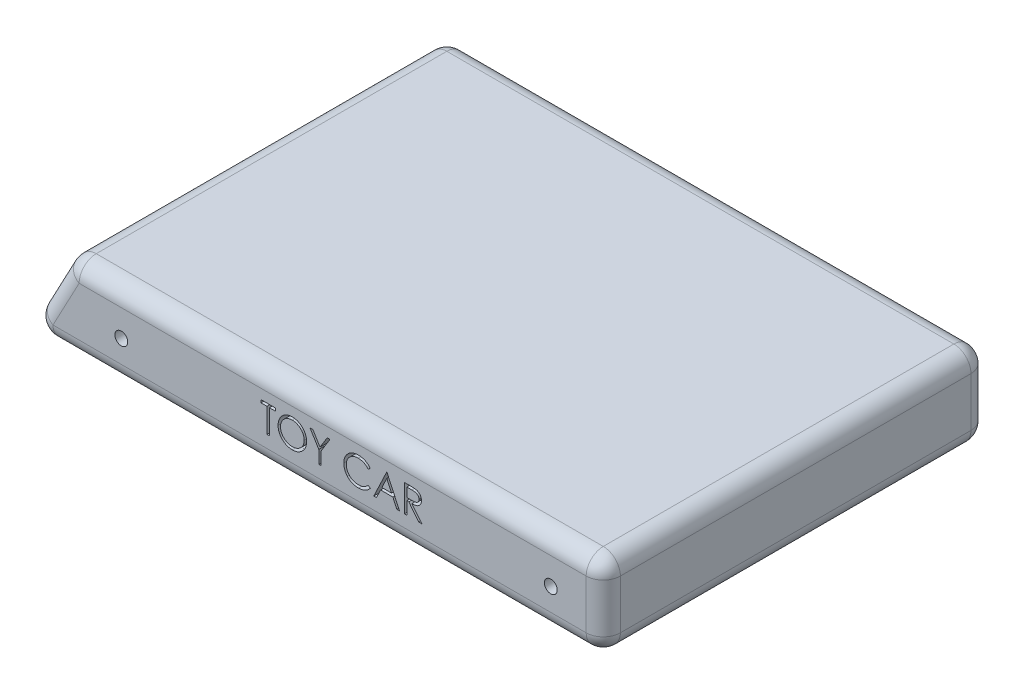
from build123d import *

# Parameters (mm, degrees)
SKETCH1_W               = 250
SKETCH1_H               = 180
BOSS_EXTRUDE1_DEPTH     = 39
SKETCH2_R               = 3
CUT_EXTRUDE2_DEPTH      = 91
CUT_EXTRUDE2_DEPTH_BACK = 91
DRAFT1_ANGLE            = 28
FILLET1_R               = 8
CUT_EXTRUDE3_DEPTH      = 8
CUT_EXTRUDE3_DEPTH_BACK = 8


with BuildPart() as part:
    # Sketch1 → Boss-Extrude1 (new body)
    with BuildSketch(Plane(origin=(0, 0, 0), x_dir=(1, 0, 0), z_dir=(0, 1, 0))):
        Rectangle(SKETCH1_W, SKETCH1_H)
    extrude(amount=BOSS_EXTRUDE1_DEPTH)

    # Sketch2 → Cut-Extrude2 (cut, two sides)
    with BuildSketch(Plane.XY) as cut_extrude2_sk:
        with Locations((100.46336903, 18.512298338)):
            Circle(SKETCH2_R)
        with Locations((-100.46336903, 18.512298338)):
            Circle(SKETCH2_R)
    extrude(amount=CUT_EXTRUDE2_DEPTH, mode=Mode.SUBTRACT)
    extrude(cut_extrude2_sk.sketch, amount=-CUT_EXTRUDE2_DEPTH_BACK, mode=Mode.SUBTRACT)

    # Draft1
    draft1_faces = [part.faces().sort_by_distance(p)[0] for p in [
        (-125, 19.5, 0),
    ]]
    draft(draft1_faces, Plane.ZX.offset(39), DRAFT1_ANGLE)

    # Fillet1
    fillet1_edges = [part.edges().sort_by_distance(p)[0] for p in [
        (-125, 39, 0),
        (0, 39, 90),
        (125, 39, 0),
        (-10.368333917, 0, 90),
        (-145.736667835, 0, 0),
        (-10.368333917, 0, -90),
        (125, 0, 0),
        (0, 39, -90),
        (125, 19.5, 90),
        (-135.368333917, 19.5, 90),
        (-135.368333917, 19.5, -90),
        (125, 19.5, -90),
    ]]
    fillet(fillet1_edges, radius=FILLET1_R)

    # Sketch3 → Cut-Extrude3 (cut, two sides)
    with BuildSketch(Plane.XY.offset(83)) as cut_extrude3_sk:
        Polygon((-35.112238837, 25.112326164), (-35.112238837, 26.414890267), (-28.436597812, 26.414890267), (-28.436597812, 25.112326164), (-31.20454653, 25.112326164), (-31.20454653, 13.714890267), (-32.34429012, 13.714890267), (-32.34429012, 25.112326164), align=None)
        with BuildLine():
            add(Edge.make_bspline(
                [(-20.53980294, 26.740531292), (-20.304642099, 26.734575067), (-19.842766804, 26.722876549), (-19.163952175, 26.633326659), (-18.515907115, 26.478403387), (-17.893352612, 26.272071994), (-17.30373524, 25.996828938), (-16.742616972, 25.664142828), (-16.211332887, 25.27052825), (-15.717043874, 24.819027912), (-15.264717226, 24.327779379), (-14.866206153, 23.803530963), (-14.532224116, 23.249452452), (-14.257955688, 22.667208866), (-14.042786447, 22.058116982), (-13.894308775, 21.418929601), (-13.79946463, 20.753788183), (-13.788376523, 20.300119274), (-13.782751658, 20.069978408)],
                knots=[0, 0, 0, 0, 0.000705368, 0.001385402, 0.00204938, 0.002701839, 0.003349503, 0.003997423, 0.004655841, 0.005329419, 0.006002834, 0.006656665, 0.007301525, 0.007939971, 0.008584465, 0.009235478, 0.009905767, 0.010595886, 0.010595886, 0.010595886, 0.010595886], degree=3))
            add(Edge.make_bspline(
                [(-13.782751658, 20.069978408), (-13.788375699, 19.841532817), (-13.799461335, 19.391240091), (-13.894416613, 18.730319594), (-14.043336813, 18.094990495), (-14.255957551, 17.486313412), (-14.528918572, 16.903646252), (-14.865124479, 16.348522162), (-15.261151158, 15.820759154), (-15.711844589, 15.326138911), (-16.203156941, 14.872576661), (-16.730135338, 14.47735674), (-17.280928242, 14.13727206), (-17.862623469, 13.865914157), (-18.467506459, 13.649027474), (-19.100990889, 13.501153645), (-19.760108385, 13.405769231), (-20.20958317, 13.39481633), (-20.43804012, 13.389249241)],
                knots=[0, 0, 0, 0, 0.000685036, 0.001350284, 0.001998823, 0.002640075, 0.003280822, 0.003925683, 0.00458358, 0.005257158, 0.005930573, 0.006586435, 0.007230442, 0.007868887, 0.008508583, 0.009154647, 0.009817376, 0.010502411, 0.010502411, 0.010502411, 0.010502411], degree=3))
            add(Edge.make_bspline(
                [(-20.43804012, 13.389249241), (-20.668179791, 13.394871302), (-21.121846346, 13.40595388), (-21.787823589, 13.500954978), (-22.427459974, 13.649513423), (-23.038926334, 13.861819092), (-23.62256365, 14.136201614), (-24.179513378, 14.47077179), (-24.707539998, 14.867763416), (-25.202265764, 15.318310701), (-25.65492714, 15.808790333), (-26.049568304, 16.334331773), (-26.384213715, 16.88462443), (-26.65767495, 17.461195446), (-26.874171702, 18.061257538), (-27.021872043, 18.688813442), (-27.117433926, 19.340285363), (-27.128446083, 19.783852451), (-27.134033709, 20.008920715)],
                knots=[0, 0, 0, 0, 0.000690119, 0.001360408, 0.002013897, 0.002657552, 0.003298299, 0.003945339, 0.004603236, 0.005276814, 0.005950229, 0.006602529, 0.007245213, 0.007879059, 0.008513962, 0.009155077, 0.009810248, 0.010485118, 0.010485118, 0.010485118, 0.010485118], degree=3))
            add(Edge.make_bspline(
                [(-27.134033709, 20.008920715), (-27.132093746, 20.159987829), (-27.128238293, 20.460216277), (-27.081822724, 20.906046512), (-27.014470265, 21.344706899), (-26.917943325, 21.774950053), (-26.791699276, 22.195722769), (-26.642739063, 22.609926965), (-26.460803052, 23.013365049), (-26.255133272, 23.407948213), (-26.025583283, 23.787525471), (-25.772034135, 24.146317101), (-25.503391512, 24.487333861), (-25.208884341, 24.801738704), (-24.898218954, 25.098677971), (-24.566355697, 25.373588401), (-24.215319553, 25.628948938), (-23.843600061, 25.859074175), (-23.460356606, 26.067205892), (-23.065289441, 26.245810895), (-22.663764167, 26.399103746), (-22.253900159, 26.523349026), (-21.836785815, 26.6214367), (-21.411510768, 26.688229098), (-20.978413821, 26.734763051), (-20.686635606, 26.738600273), (-20.53980294, 26.740531292)],
                knots=[0, 0, 0, 0, 0.000453023, 0.000900331, 0.00134327, 0.001783953, 0.002221843, 0.002660465, 0.003103469, 0.003548398, 0.003994743, 0.004433047, 0.004865726, 0.005295975, 0.005724256, 0.006154227, 0.006587795, 0.007025471, 0.007464852, 0.007895214, 0.008325184, 0.00875333, 0.009179133, 0.00960951, 0.010044159, 0.010484467, 0.010484467, 0.010484467, 0.010484467], degree=3))
        make_face()
        with BuildLine():
            add(Edge.make_bspline(
                [(-20.483833389, 25.43796719), (-20.604355059, 25.436498016), (-20.844246204, 25.433573715), (-21.200878664, 25.395053833), (-21.552820824, 25.34015395), (-21.900145367, 25.261843861), (-22.241399046, 25.155149155), (-22.579762755, 25.032355002), (-22.912150979, 24.882781331), (-23.237466406, 24.713788946), (-23.552843964, 24.526740005), (-23.85043291, 24.320013879), (-24.131003646, 24.098458554), (-24.393869214, 23.861556972), (-24.638257753, 23.608102703), (-24.868979384, 23.341938149), (-25.076786152, 23.055455573), (-25.267233816, 22.756423525), (-25.437659979, 22.445231502), (-25.589208552, 22.125155716), (-25.713175099, 21.793585253), (-25.814275721, 21.454117309), (-25.898095035, 21.107289527), (-25.951195274, 20.750470876), (-25.990138406, 20.385454326), (-25.99289556, 20.138777313), (-25.99429012, 20.014008856)],
                knots=[0, 0, 0, 0, 0.000361401, 0.000719348, 0.001074863, 0.001429731, 0.001786237, 0.002146831, 0.002508984, 0.002878794, 0.003246164, 0.003608191, 0.003964987, 0.004318036, 0.004668869, 0.005020697, 0.005373837, 0.005729543, 0.006083645, 0.0064376, 0.006791042, 0.007144375, 0.007499817, 0.007860358, 0.0082259, 0.008600016, 0.008600016, 0.008600016, 0.008600016], degree=3))
            add(Edge.make_bspline(
                [(-25.99429012, 20.014008856), (-25.989664192, 19.830540227), (-25.980563561, 19.469600674), (-25.900888949, 18.940670552), (-25.778163499, 18.432350198), (-25.597252484, 17.947420985), (-25.371008825, 17.481714587), (-25.091511252, 17.039362321), (-24.760371141, 16.620244634), (-24.38422063, 16.227287516), (-23.973021095, 15.868618455), (-23.536385189, 15.553791229), (-23.078990671, 15.287416894), (-22.599644764, 15.070409917), (-22.100906551, 14.898452868), (-21.579562294, 14.780601835), (-21.039084912, 14.703039469), (-20.670673678, 14.695590897), (-20.483833389, 14.691813343)],
                knots=[0, 0, 0, 0, 0.000550108, 0.001082232, 0.001601154, 0.002116289, 0.002631707, 0.003151905, 0.003682739, 0.004231557, 0.004781529, 0.005317417, 0.005844089, 0.006366671, 0.006893638, 0.007423745, 0.007968111, 0.008528275, 0.008528275, 0.008528275, 0.008528275], degree=3))
            add(Edge.make_bspline(
                [(-20.483833389, 14.691813343), (-20.35825034, 14.693538745), (-20.109181437, 14.696960735), (-19.738720541, 14.731427362), (-19.374933716, 14.786697288), (-19.018331215, 14.866274238), (-18.669317756, 14.965868387), (-18.326436613, 15.084187857), (-17.99333996, 15.231802511), (-17.665825691, 15.394899364), (-17.352330757, 15.580827935), (-17.053062397, 15.780537793), (-16.775563842, 16.001766788), (-16.512894925, 16.235148565), (-16.267503025, 16.485388813), (-16.041047568, 16.752162189), (-15.834291089, 17.037152574), (-15.643915742, 17.335731046), (-15.47408676, 17.647774592), (-15.326116887, 17.969010852), (-15.200582409, 18.29864882), (-15.099241835, 18.637163951), (-15.019828874, 18.983913316), (-14.965110307, 19.3393612), (-14.926834544, 19.702796528), (-14.92394955, 19.948609949), (-14.922495248, 20.072522478)],
                knots=[0, 0, 0, 0, 0.00037666, 0.00074703, 0.001115112, 0.001479909, 0.001842294, 0.002203561, 0.002567016, 0.002934509, 0.003300581, 0.003659737, 0.00401296, 0.004364308, 0.004713319, 0.005063497, 0.005413082, 0.005768788, 0.006125121, 0.006478005, 0.006829068, 0.007182401, 0.00753727, 0.007895297, 0.008260839, 0.008632412, 0.008632412, 0.008632412, 0.008632412], degree=3))
            add(Edge.make_bspline(
                [(-14.922495248, 20.072522478), (-14.923950715, 20.195587308), (-14.926837902, 20.439709067), (-14.965092024, 20.800609751), (-15.019886683, 21.153499975), (-15.098854224, 21.496994346), (-15.20063621, 21.831180423), (-15.326138809, 22.155744336), (-15.474131182, 22.471895215), (-15.643978167, 22.778851664), (-15.834898441, 23.073399999), (-16.04352041, 23.354985896), (-16.273446101, 23.618321272), (-16.518106249, 23.869907162), (-16.783612033, 24.10437779), (-17.068760757, 24.321810936), (-17.370090673, 24.52745396), (-17.689140928, 24.712966713), (-18.018411846, 24.884286929), (-18.356282493, 25.031066283), (-18.698925226, 25.155787973), (-19.045468719, 25.262166675), (-19.398829812, 25.339847242), (-19.756620848, 25.395103308), (-20.118346815, 25.433560308), (-20.361617927, 25.436493568), (-20.483833389, 25.43796719)],
                knots=[0, 0, 0, 0, 0.000369031, 0.00073204, 0.001087555, 0.001439943, 0.001788407, 0.002134718, 0.002482986, 0.00283486, 0.003186283, 0.003535331, 0.003885231, 0.004234241, 0.004587492, 0.004946738, 0.005309426, 0.005681174, 0.006053244, 0.006422379, 0.006785362, 0.007146737, 0.00750905, 0.007869591, 0.0082326, 0.008599088, 0.008599088, 0.008599088, 0.008599088], degree=3))
        make_face(mode=Mode.SUBTRACT)
        Polygon((-12.15454653, 26.414890267), (-10.849438357, 26.414890267), (-7.511617844, 20.957859017), (-4.178885472, 26.414890267), (-2.873777299, 26.414890267), (-6.94429012, 19.751969593), (-6.94429012, 13.714890267), (-8.084033709, 13.714890267), (-8.084033709, 19.751969593), align=None)
        with BuildLine():
            Line((16.013402188, 24.084521677), (15.016126547, 23.321300523))
            add(Edge.make_bspline(
                [(15.016126547, 23.321300523), (14.944985181, 23.406085613), (14.803661588, 23.574512708), (14.576298196, 23.81102134), (14.33934652, 24.032601003), (14.092897138, 24.240307252), (13.832514047, 24.426876659), (13.564504863, 24.602031804), (13.284386242, 24.759031882), (12.897029948, 24.949397575), (12.390307755, 25.148047908), (11.752423625, 25.314611062), (11.086540496, 25.420642185), (10.632252063, 25.432126038), (10.401182637, 25.43796719)],
                knots=[0, 0, 0, 0, 0.00033196, 0.000659444, 0.000983431, 0.001304932, 0.001625525, 0.001943778, 0.002265016, 0.002588143, 0.003238217, 0.003893566, 0.004562806, 0.005255583, 0.005255583, 0.005255583, 0.005255583], degree=3))
            add(Edge.make_bspline(
                [(10.401182637, 25.43796719), (10.273880379, 25.436501383), (10.020457349, 25.433583373), (9.64436146, 25.395087405), (9.275288388, 25.340981014), (8.913478211, 25.260697698), (8.559391476, 25.159197052), (8.210713331, 25.03791055), (7.872492012, 24.88785156), (7.54004869, 24.721995873), (7.221535553, 24.534662002), (6.92016438, 24.330324983), (6.637034325, 24.111271404), (6.371921418, 23.876680247), (6.124554634, 23.62760799), (5.896726392, 23.361400237), (5.689225046, 23.078908064), (5.497937555, 22.783856557), (5.32662278, 22.477105141), (5.183185789, 22.157518457), (5.056167203, 21.830569283), (4.955658522, 21.492563643), (4.876103847, 21.145879892), (4.82121204, 20.789587604), (4.783153873, 20.42443111), (4.780250374, 20.176928747), (4.778786804, 20.052169914)],
                knots=[0, 0, 0, 0, 0.000381746, 0.00075995, 0.001133062, 0.001500343, 0.001870765, 0.002237676, 0.002606812, 0.002979993, 0.003351741, 0.00371443, 0.004071661, 0.004424911, 0.004775707, 0.005123948, 0.005475039, 0.005826461, 0.006178335, 0.006527846, 0.006876532, 0.007229865, 0.007584733, 0.007942761, 0.008310834, 0.008684951, 0.008684951, 0.008684951, 0.008684951], degree=3))
            add(Edge.make_bspline(
                [(4.778786804, 20.052169914), (4.783365404, 19.864459125), (4.792354879, 19.495913888), (4.872358834, 18.956089101), (4.993934451, 18.438942656), (5.176145258, 17.947707229), (5.400822956, 17.476325472), (5.684724604, 17.032773061), (6.013533182, 16.610347241), (6.391900361, 16.219031403), (6.807030036, 15.861567314), (7.252429601, 15.546786632), (7.726989731, 15.284386916), (8.225470647, 15.066034196), (8.75170826, 14.898188355), (9.304756257, 14.780027107), (9.883411783, 14.702948338), (10.278815034, 14.695568955), (10.480048823, 14.691813343)],
                knots=[0, 0, 0, 0, 0.000562815, 0.001105012, 0.001633818, 0.00215373, 0.002673724, 0.003197432, 0.003730267, 0.004277248, 0.00482748, 0.005371661, 0.005910344, 0.006451519, 0.007001839, 0.007564217, 0.008146414, 0.008749794, 0.008749794, 0.008749794, 0.008749794], degree=3))
            add(Edge.make_bspline(
                [(10.480048823, 14.691813343), (10.701764294, 14.697941201), (11.138153381, 14.710002292), (11.778117362, 14.812180139), (12.390749998, 14.977853155), (12.97608424, 15.20971133), (13.532469956, 15.51111966), (14.060777838, 15.876509101), (14.561453822, 16.309355337), (14.862521047, 16.639856974), (15.016126547, 16.80848001)],
                knots=[0, 0, 0, 0, 0.000664826, 0.001308536, 0.001938654, 0.00256556, 0.003192755, 0.00383282, 0.004489298, 0.005173128, 0.005173128, 0.005173128, 0.005173128], degree=3))
            Line((15.016126547, 16.80848001), (16.013402188, 16.052891068))
            add(Edge.make_bspline(
                [(16.013402188, 16.052891068), (15.933145047, 15.949337257), (15.773015191, 15.742725651), (15.513724672, 15.451454019), (15.240575621, 15.177482233), (14.951539188, 14.92301915), (14.649940344, 14.682972946), (14.330363668, 14.464163444), (13.997010321, 14.263536521), (13.651009784, 14.079833109), (13.292729674, 13.91684767), (12.922599296, 13.777315427), (12.542214065, 13.657119399), (12.151556592, 13.5582338), (11.74981656, 13.481050153), (11.338443697, 13.429453047), (10.916550149, 13.394103815), (10.63191985, 13.390881949), (10.487681034, 13.389249241)],
                knots=[0, 0, 0, 0, 0.00039295, 0.000784017, 0.001168988, 0.001552873, 0.001938676, 0.002324679, 0.002713864, 0.003105353, 0.00349929, 0.003893826, 0.004291304, 0.004695459, 0.005102104, 0.005517692, 0.005938765, 0.006371376, 0.006371376, 0.006371376, 0.006371376], degree=3))
            add(Edge.make_bspline(
                [(10.487681034, 13.389249241), (10.3510883, 13.3901999), (10.080993081, 13.392079709), (9.682217611, 13.422531288), (9.293998275, 13.464077477), (8.917444633, 13.526634524), (8.550501809, 13.600455415), (8.196496259, 13.699411117), (7.851944496, 13.81026095), (7.518230803, 13.940544759), (7.195071321, 14.087560622), (6.883508348, 14.253718564), (6.583685179, 14.43762133), (6.29265408, 14.635215225), (6.014714277, 14.852847149), (5.747457199, 15.087494651), (5.489384214, 15.338366862), (5.329717328, 15.519268758), (5.249439848, 15.610222799)],
                knots=[0, 0, 0, 0, 0.000409666, 0.000810065, 0.001199174, 0.001580615, 0.001954827, 0.00232143, 0.002682661, 0.003040299, 0.003395496, 0.003747176, 0.004098847, 0.004450261, 0.004801913, 0.005157073, 0.005516877, 0.005880706, 0.005880706, 0.005880706, 0.005880706], degree=3))
            add(Edge.make_bspline(
                [(5.249439848, 15.610222799), (5.120859085, 15.768215113), (4.865249898, 16.082292319), (4.538222417, 16.591330022), (4.258287003, 17.12280038), (4.031951519, 17.67949555), (3.855012458, 18.260166356), (3.732434979, 18.865105508), (3.652782014, 19.493748041), (3.643673252, 19.921327246), (3.639043214, 20.138668311)],
                knots=[0, 0, 0, 0, 0.000610709, 0.001214046, 0.001811469, 0.002410515, 0.003014109, 0.003629806, 0.004260284, 0.004912063, 0.004912063, 0.004912063, 0.004912063], degree=3))
            add(Edge.make_bspline(
                [(3.639043214, 20.138668311), (3.644686345, 20.367106671), (3.655788852, 20.816544883), (3.750116453, 21.476124657), (3.901858942, 22.108045447), (4.117384795, 22.711127606), (4.390635641, 23.288543194), (4.728189354, 23.83588128), (5.126124413, 24.356642239), (5.581319873, 24.842924337), (6.080492776, 25.28756713), (6.615049615, 25.678749641), (7.183944108, 26.004296056), (7.780908884, 26.276424989), (8.410414071, 26.48559204), (9.071116582, 26.632016461), (9.76177493, 26.723155711), (10.232990017, 26.73467718), (10.472416611, 26.740531292)],
                knots=[0, 0, 0, 0, 0.000685036, 0.001347765, 0.001994424, 0.002631723, 0.003265569, 0.003907406, 0.004557186, 0.005228594, 0.005902557, 0.006560016, 0.007211953, 0.007865497, 0.008525192, 0.009197944, 0.009893113, 0.01061119, 0.01061119, 0.01061119, 0.01061119], degree=3))
            add(Edge.make_bspline(
                [(10.472416611, 26.740531292), (10.618337695, 26.738781819), (10.907173785, 26.735318914), (11.334447696, 26.701550913), (11.750435568, 26.645258684), (12.155423988, 26.568637517), (12.551383195, 26.473542379), (12.935286927, 26.349661868), (13.309387876, 26.208015026), (13.671326657, 26.044880021), (14.019366711, 25.861757845), (14.353399638, 25.660678296), (14.670772125, 25.441890659), (14.973717375, 25.207255708), (15.257167627, 24.951809508), (15.529170706, 24.682578231), (15.780489475, 24.391806926), (15.935622497, 24.187137594), (16.013402188, 24.084521677)],
                knots=[0, 0, 0, 0, 0.000437698, 0.00086638, 0.001284824, 0.001696468, 0.002102476, 0.002505573, 0.002905769, 0.003302024, 0.003695764, 0.004084948, 0.004470952, 0.004851611, 0.005233595, 0.005614968, 0.005999089, 0.006385327, 0.006385327, 0.006385327, 0.006385327], degree=3))
        make_face()
        Polygon((23.828786804, 26.414890267), (29.690325265, 13.714890267), (28.451362925, 13.714890267), (26.573838887, 17.785403087), (20.816607316, 17.785403087), (18.885657797, 13.714890267), (17.641607316, 13.714890267), (23.665966291, 26.414890267), align=None)
        Polygon((23.734656195, 23.939509658), (21.434816451, 19.08796719), (25.973438246, 19.08796719), align=None, mode=Mode.SUBTRACT)
        with BuildLine():
            Line((31.969812445, 26.414890267), (34.511338887, 26.414890267))
            add(Edge.make_bspline(
                [(34.511338887, 26.414890267), (34.68094241, 26.414325712), (35.006599963, 26.413241704), (35.473137258, 26.407197364), (35.897052724, 26.389873273), (36.278124713, 26.374964985), (36.616346232, 26.347779941), (36.912754402, 26.321797021), (37.165984047, 26.287784023), (37.319276136, 26.256195774), (37.388682637, 26.241893472)],
                knots=[0, 0, 0, 0, 0.00050882, 0.000976992, 0.001399583, 0.001781609, 0.002120925, 0.002417362, 0.00267425, 0.002886798, 0.002886798, 0.002886798, 0.002886798], degree=3))
            add(Edge.make_bspline(
                [(37.388682637, 26.241893472), (37.481598102, 26.218936352), (37.665446892, 26.173511849), (37.930151417, 26.077501298), (38.182389107, 25.966395803), (38.421112184, 25.835898875), (38.645124912, 25.685041817), (38.856737068, 25.516428916), (39.056908893, 25.330982769), (39.237545093, 25.124027773), (39.407866795, 24.906906723), (39.551516954, 24.67212452), (39.675347324, 24.426609834), (39.773937485, 24.167865775), (39.853323275, 23.898401632), (39.909298486, 23.615776569), (39.942867081, 23.321278174), (39.946284671, 23.120408048), (39.948017573, 23.018556132)],
                knots=[0, 0, 0, 0, 0.00028695, 0.000567779, 0.000843397, 0.001113237, 0.001382776, 0.001652556, 0.001924343, 0.002200055, 0.002475849, 0.002751185, 0.003024244, 0.003299685, 0.003580653, 0.003866043, 0.004163002, 0.00446846, 0.00446846, 0.00446846, 0.00446846], degree=3))
            add(Edge.make_bspline(
                [(39.948017573, 23.018556132), (39.942687208, 22.849337324), (39.932286286, 22.5191476), (39.835312339, 22.039955259), (39.67646611, 21.592954032), (39.457578747, 21.178706746), (39.178833792, 20.805288118), (38.843826693, 20.477299895), (38.45237056, 20.202835069), (38.087955614, 20.01250632), (37.766049803, 19.890612052), (37.501043211, 19.804845836), (37.211965893, 19.73858099), (36.901587564, 19.679217083), (36.568616586, 19.634398078), (36.213851014, 19.601571864), (35.837037836, 19.581055744), (35.578178927, 19.578000469), (35.445012765, 19.576428728)],
                knots=[0, 0, 0, 0, 0.00050719, 0.000989658, 0.001459589, 0.001926202, 0.002389733, 0.002852089, 0.003326461, 0.003819151, 0.004080894, 0.004358478, 0.00465405, 0.004969894, 0.005306299, 0.005661468, 0.00603854, 0.006438032, 0.006438032, 0.006438032, 0.006438032], degree=3))
            Line((35.445012765, 19.576428728), (40.110838086, 13.714890267))
            Line((40.110838086, 13.714890267), (38.701423022, 13.714890267))
            Line((38.701423022, 13.714890267), (34.035597701, 19.576428728))
            Line((34.035597701, 19.576428728), (33.109556034, 19.576428728))
            Line((33.109556034, 19.576428728), (33.109556034, 13.714890267))
            Line((33.109556034, 13.714890267), (31.969812445, 13.714890267))
            Line((31.969812445, 13.714890267), (31.969812445, 26.414890267))
        make_face()
        with BuildLine():
            Line((33.109556034, 25.112326164), (33.109556034, 20.878992831))
            Line((33.109556034, 20.878992831), (35.434836483, 20.861184337))
            add(Edge.make_bspline(
                [(35.434836483, 20.861184337), (35.543403481, 20.861136307), (35.753837246, 20.861043211), (36.058276801, 20.875534913), (36.341741206, 20.892020668), (36.603146221, 20.917236865), (36.842608623, 20.949734611), (37.060008723, 20.990385439), (37.255701397, 21.037745781), (37.483933236, 21.111048823), (37.738791507, 21.227184946), (38.015765661, 21.396151184), (38.251631287, 21.608673417), (38.450904673, 21.851691386), (38.611031467, 22.118885775), (38.723923779, 22.407053743), (38.795560641, 22.708920399), (38.804009934, 22.916395247), (38.808273983, 23.021100202)],
                knots=[0, 0, 0, 0, 0.000325651, 0.000631204, 0.000914157, 0.001177428, 0.001418847, 0.001638891, 0.00184066, 0.002022485, 0.00235726, 0.002678438, 0.002991969, 0.003304683, 0.003618388, 0.003922157, 0.004230116, 0.004543873, 0.004543873, 0.004543873, 0.004543873], degree=3))
            add(Edge.make_bspline(
                [(38.808273983, 23.021100202), (38.803912001, 23.123232056), (38.795268144, 23.325620122), (38.724696898, 23.621914425), (38.605355428, 23.901557358), (38.444529022, 24.163411347), (38.248589231, 24.401103588), (38.018836025, 24.604474686), (37.76155146, 24.772294172), (37.521081683, 24.879534353), (37.306146112, 24.945283535), (37.119529917, 24.991552044), (36.908668269, 25.028724831), (36.67253732, 25.058508366), (36.412145116, 25.084107735), (36.12617504, 25.101349903), (35.816524437, 25.11156021), (35.601905572, 25.112064904), (35.490806034, 25.112326164)],
                knots=[0, 0, 0, 0, 0.000306146, 0.000606669, 0.000907656, 0.001214825, 0.001525577, 0.001828332, 0.00213176, 0.0024438, 0.002614386, 0.002805665, 0.003020244, 0.003256281, 0.003519552, 0.003805044, 0.004115587, 0.00444887, 0.00444887, 0.00444887, 0.00444887], degree=3))
            Line((35.490806034, 25.112326164), (33.109556034, 25.112326164))
        make_face(mode=Mode.SUBTRACT)
    extrude(amount=CUT_EXTRUDE3_DEPTH, mode=Mode.SUBTRACT)
    extrude(cut_extrude3_sk.sketch, amount=-CUT_EXTRUDE3_DEPTH_BACK, mode=Mode.SUBTRACT)


solid = part.part
